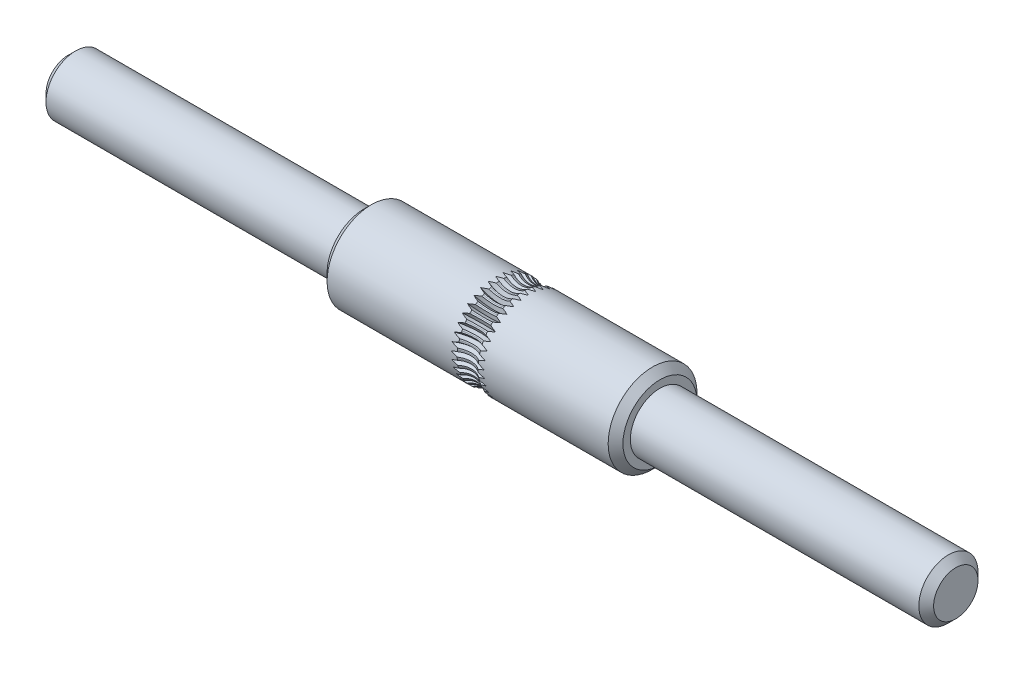
from build123d import *

# Parameters (mm, degrees)
CHAMFER1_SIZE     = 0.5
CIRPATTERN1_COUNT = 37


with BuildPart() as part:
    # Sketch1 → Revolve1 (revolve)
    with BuildSketch(Plane.XY):
        Polygon((-10, 3), (10, 3), (10, 2), (30, 2), (30, 0), (-30, 0), (-30, 2), (-10, 2), align=None)
    revolve(axis=Axis((0, 0, 0), (1, 0, 0)))

    # Chamfer1
    chamfer1_edges = [part.edges().sort_by_distance(p)[0] for p in [
        (-10, -3, 0),
        (10, -3, 0),
        (30, -2, 0),
        (-30, -2, 0),
    ]]
    chamfer(chamfer1_edges, length=CHAMFER1_SIZE)

    # Sketch2 → Cut-Revolve1 (revolve, cut)
    with BuildSketch(Plane(origin=(0, 0, 0), x_dir=(0, 0, -1), z_dir=(1, 0, 0))):
        Polygon((0.156173248, 2.7705), (0, 2.5), (-0.156173248, 2.7705), (-1.150795268, 2.7705), (-1.150795268, 4), (1.150795268, 4), (1.150795268, 2.7705), align=None)
    cut_revolve1 = revolve(axis=Axis((0, 4, -9.989903303), (0, 0, 1)), mode=Mode.SUBTRACT)

    # CirPattern1: Cut-Revolve1 ×37 about axis
    cirpattern1_axis = Axis((0, 0, 0), (-1, 0, 0))
    for i in range(1, CIRPATTERN1_COUNT):
        add(cut_revolve1.rotate(cirpattern1_axis, i * 360 / CIRPATTERN1_COUNT), mode=Mode.SUBTRACT)


solid = part.part
